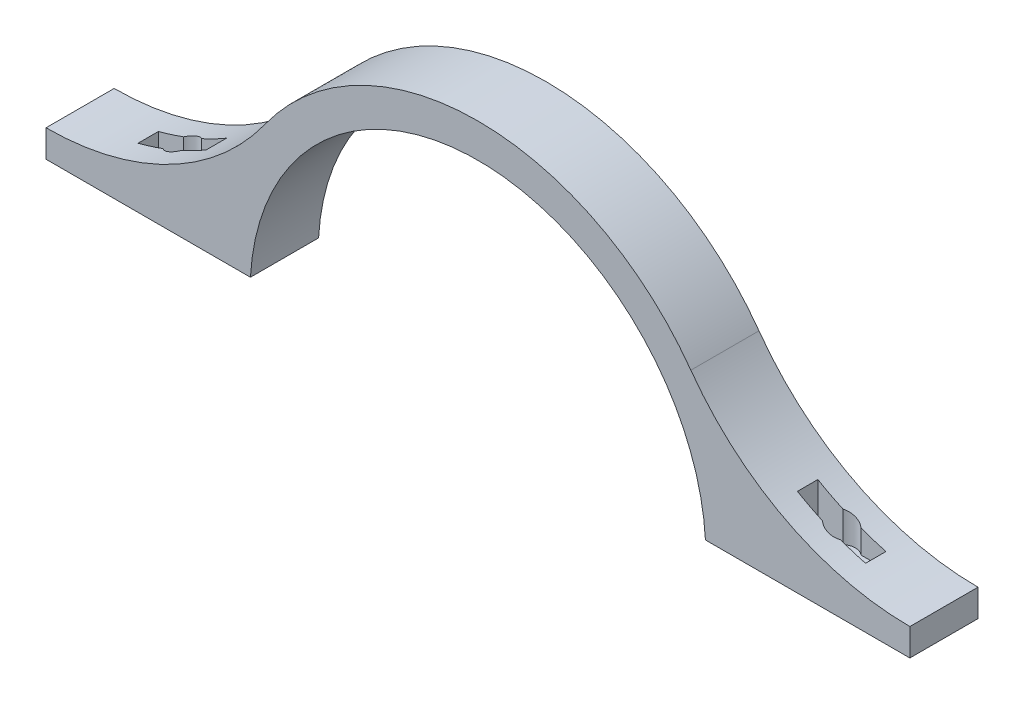
from build123d import *

# Parameters (mm, degrees)
BOSS_EXTRUDE1_DEPTH = 25.4
CUT_EXTRUDE2_DEPTH  = 23.957211
SKETCH4_R           = 2.159
BOSS_EXTRUDE2_DEPTH = 7.62


with BuildPart() as part:
    # Sketch1 → Boss-Extrude1 (new body)
    with BuildSketch(Plane.XY):
        with BuildLine():
            ThreePointArc((-160.997616832, 14.9225), (-115.11071, 26.01979846), (-79.36572698, 56.858969015))
            ThreePointArc((-79.36572698, 56.858969015), (-44.613051666, 86.842020921), (0, 97.63125))
            Line((0, 97.63125), (0, 84.93125))
            ThreePointArc((0, 84.93125), (-58.347374184, 61.716295679), (-84.797616832, 4.7625))
            Line((-84.797616832, 4.7625), (-160.997616832, 4.7625))
            Line((-160.997616832, 4.7625), (-160.997616832, 14.9225))
        make_face()
    boss_extrude1 = extrude(amount=-BOSS_EXTRUDE1_DEPTH)

    # Sketch3 → Cut-Extrude2 (cut)
    with BuildSketch(Plane.XZ.offset(-4.7625)):
        with BuildLine():
            Line((-119.537512667, -16.51), (-110.197616832, -16.51))
            Line((-110.197616832, -16.51), (-110.197616832, -8.89))
            Line((-110.197616832, -8.89), (-119.537512667, -8.89))
            ThreePointArc((-119.537512667, -8.89), (-122.897616832, -7.62), (-126.257720997, -8.89))
            Line((-126.257720997, -8.89), (-135.597616832, -8.89))
            Line((-135.597616832, -8.89), (-135.597616832, -16.51))
            Line((-135.597616832, -16.51), (-126.257720997, -16.51))
            ThreePointArc((-126.257720997, -16.51), (-122.897616832, -17.78), (-119.537512667, -16.51))
        make_face()
    cut_extrude2 = extrude(amount=-CUT_EXTRUDE2_DEPTH, mode=Mode.SUBTRACT)

    # Mirror2: Boss-Extrude1, Cut-Extrude2 across plane
    add(boss_extrude1.mirror(Plane(origin=(0, 0, -25.4), x_dir=(0, 0, 1), z_dir=(-1, 0, 0))))
    add(cut_extrude2.mirror(Plane(origin=(0, 0, -25.4), x_dir=(0, 0, 1), z_dir=(-1, 0, 0))), mode=Mode.SUBTRACT)

    # Sketch4 → Boss-Extrude2 (add)
    with BuildSketch(Plane.XZ.offset(-4.7625)):
        with BuildLine():
            Line((-110.197616832, -8.89), (-119.537512667, -8.89))
            ThreePointArc((-119.537512667, -8.89), (-122.897616832, -7.62), (-126.257720997, -8.89))
            Line((-126.257720997, -8.89), (-135.597616832, -8.89))
            Line((-135.597616832, -8.89), (-135.597616832, -16.51))
            Line((-135.597616832, -16.51), (-126.257720997, -16.51))
            ThreePointArc((-126.257720997, -16.51), (-122.897616832, -17.78), (-119.537512667, -16.51))
            Line((-119.537512667, -16.51), (-110.197616832, -16.51))
            Line((-110.197616832, -16.51), (-110.197616832, -8.89))
        make_face()
        with Locations((-122.897616832, -12.7)):
            Circle(SKETCH4_R, mode=Mode.SUBTRACT)
    boss_extrude2 = extrude(amount=-BOSS_EXTRUDE2_DEPTH)

    # Mirror3: Boss-Extrude2 across plane
    add(boss_extrude2.mirror(Plane(origin=(0, 0, 0), x_dir=(0, 0, 1), z_dir=(1, 0, 0))))


solid = part.part
